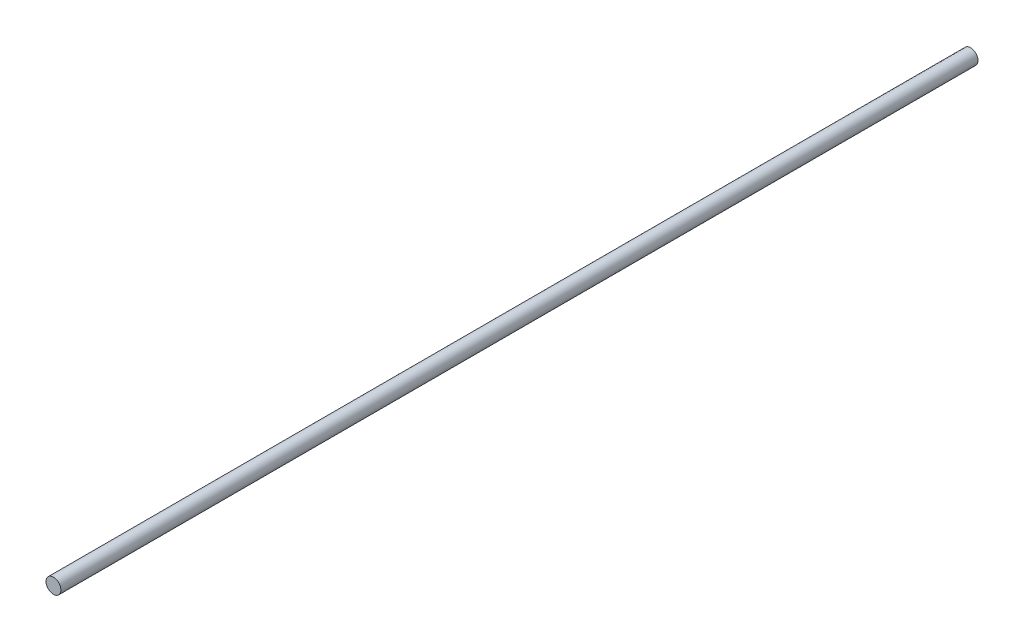
from build123d import *

# Parameters (mm, degrees)
ESBO_O1_W = 4.080244746
ESBO_O1_H = 502.48


with BuildPart() as part:
    # Esboço1 → Revolução1 (revolve)
    with BuildSketch(Plane.XZ):
        with Locations((2.040122373, 251.24)):
            Rectangle(ESBO_O1_W, ESBO_O1_H)
    revolve(axis=Axis((0, 0, 502.48), (0, 0, -1)))


solid = part.part
